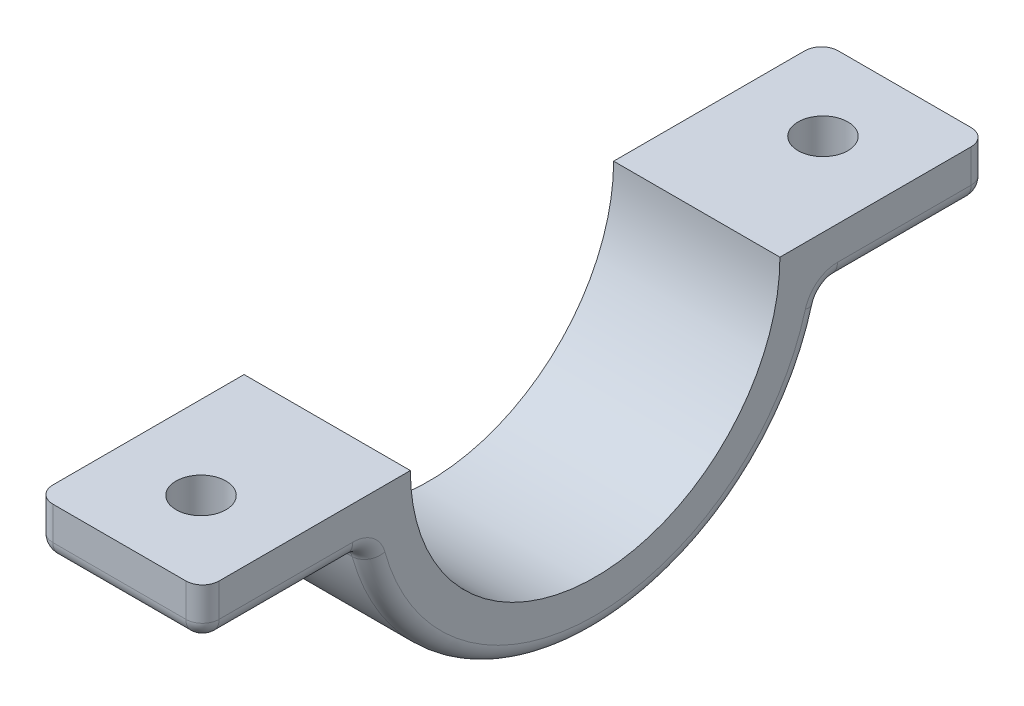
from build123d import *

# Parameters (mm, degrees)
CLAMP_EXTRUDE_DEPTH     = 10
HOLE_R                  = 1.5
HOLES_CUT_EXTRUDE_DEPTH = 4
FILLET1_R               = 1


with BuildPart() as part:
    # Sketch4 → Clamp Extrude (new body)
    with BuildSketch(Plane(origin=(0, 0, 0), x_dir=(0, 0, -1), z_dir=(1, 0, 0))):
        with BuildLine():
            Line((-23.6125, 0), (-11.1125, 0))
            ThreePointArc((-11.1125, 0), (0, -11.1125), (11.1125, 0))
            Line((11.1125, 0), (23.6125, 0))
            Line((23.6125, 0), (23.6125, -3))
            Line((23.6125, -3), (13.789947652, -3))
            ThreePointArc((13.789947652, -3), (0, -14.1125), (-13.789947652, -3))
            Line((-13.789947652, -3), (-23.6125, -3))
            Line((-23.6125, -3), (-23.6125, 0))
        make_face()
    extrude(amount=CLAMP_EXTRUDE_DEPTH)

    # Hole → Holes Cut-Extrude (cut, through all)
    with BuildSketch(Plane.XZ.offset(3)):
        with Locations((5, 18.701223826)):
            Circle(HOLE_R)
        with Locations((5, -18.701223826)):
            Circle(HOLE_R)
    extrude(amount=-HOLES_CUT_EXTRUDE_DEPTH, mode=Mode.SUBTRACT)

    # Fillet1
    fillet1_edges = [part.edges().sort_by_distance(p)[0] for p in [
        (0, -1.5, -23.6125),
        (0, -3, -18.701223826),
        (0, -14.1125, 0),
        (10, -1.5, -23.6125),
        (5, -3, 13.789947652),
        (5, -3, 23.6125),
        (5, -3, -23.6125),
        (5, -3, -13.789947652),
        (10, -1.5, 23.6125),
        (10, -3, 18.701223826),
        (10, -14.1125, 0),
        (0, -3, 18.701223826),
        (10, -3, -18.701223826),
        (0, -1.5, 23.6125),
    ]]
    fillet(fillet1_edges, radius=FILLET1_R)


solid = part.part
